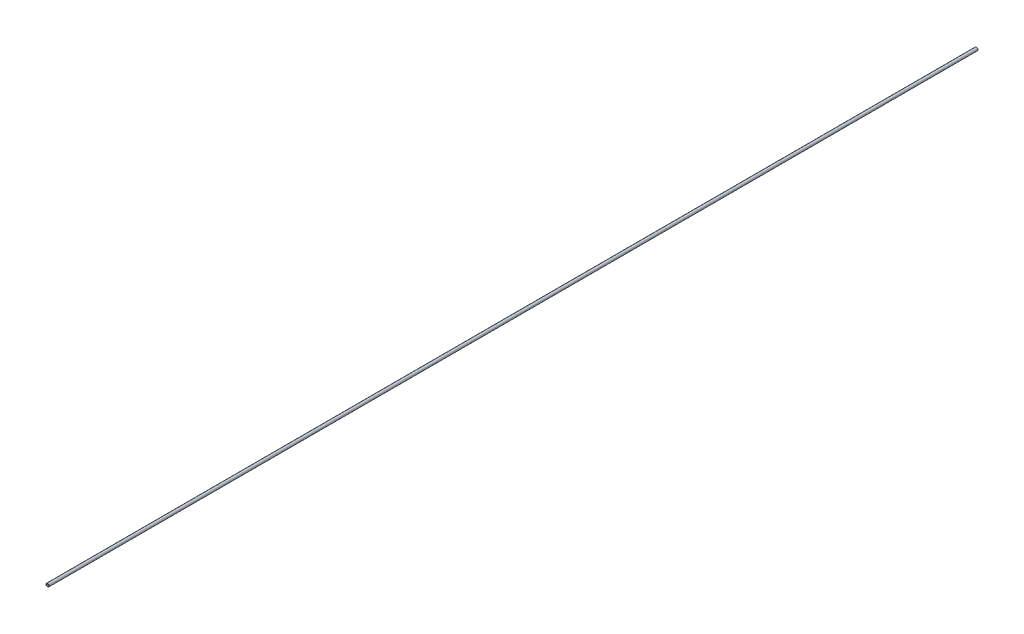
from build123d import *

# Parameters (mm, degrees)
SKETCH1_R           = 2.5
SKETCH1_R_2         = 1.6
BOSS_EXTRUDE1_DEPTH = 1000
SKETCH2_R           = 2.5
SKETCH2_R_2         = 1.6
BOSS_EXTRUDE2_DEPTH = 500


with BuildPart() as part:
    # Sketch1 → Boss-Extrude1 (new body)
    with BuildSketch(Plane.XY):
        Circle(SKETCH1_R)
        Circle(SKETCH1_R_2, mode=Mode.SUBTRACT)
    extrude(amount=BOSS_EXTRUDE1_DEPTH)

    # Sketch2 → Boss-Extrude2 (add)
    with BuildSketch(Plane.XY.offset(1000)):
        Circle(SKETCH2_R)
        Circle(SKETCH2_R_2, mode=Mode.SUBTRACT)
    extrude(amount=BOSS_EXTRUDE2_DEPTH)


solid = part.part
